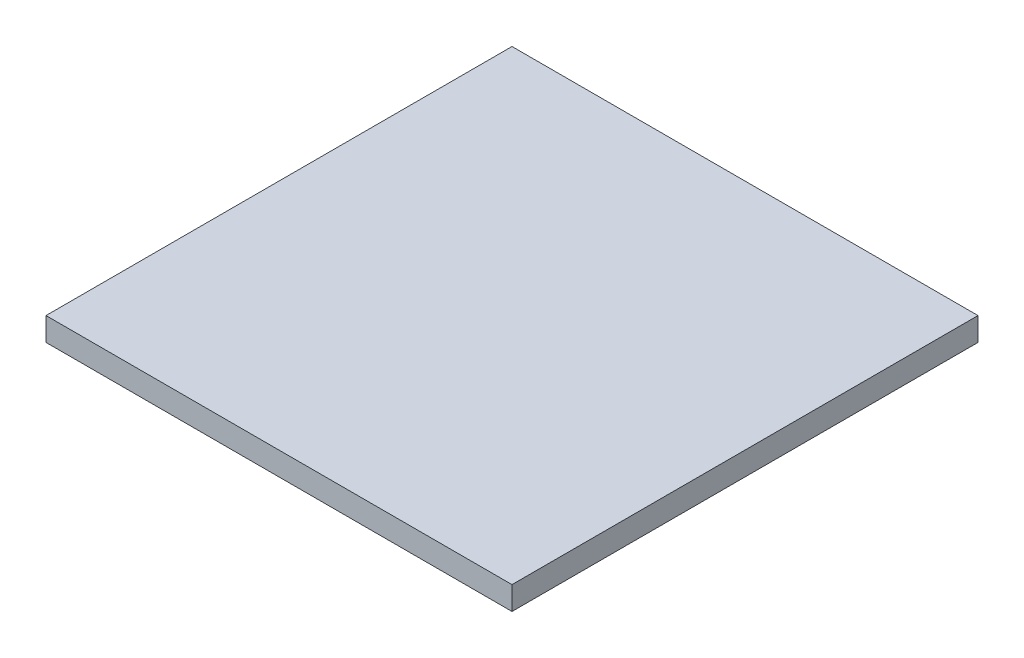
from build123d import *

# Parameters (mm, degrees)
SKETCH1_W           = 20
SKETCH1_H           = 20
BOSS_EXTRUDE1_DEPTH = 1


with BuildPart() as part:
    # Sketch1 → Boss-Extrude1 (new body)
    with BuildSketch(Plane(origin=(0, 0, 0), x_dir=(1, 0, 0), z_dir=(0, 1, 0))):
        with Locations((10, 10)):
            Rectangle(SKETCH1_W, SKETCH1_H)
    extrude(amount=BOSS_EXTRUDE1_DEPTH)


solid = part.part
